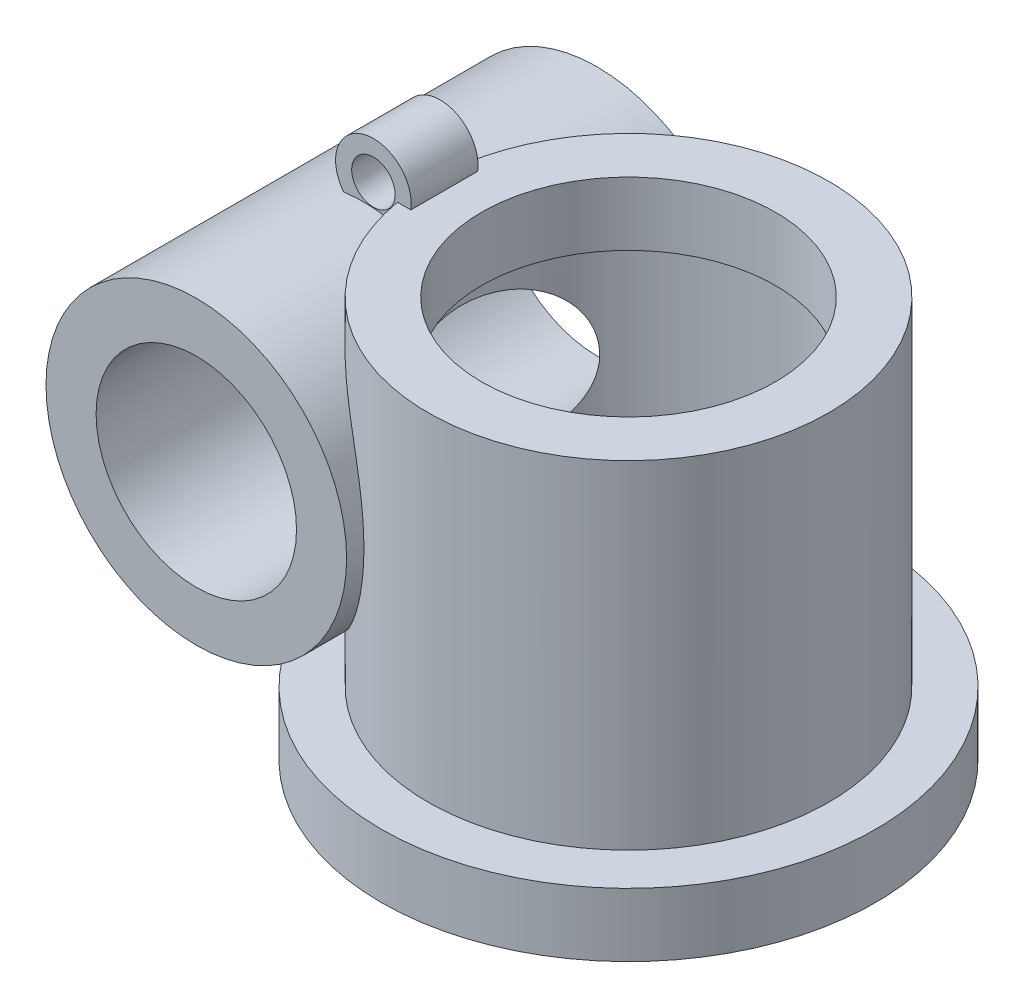
from build123d import *

# Parameters (mm, degrees)
BOSS_EXTRUDE1_DEPTH      = 5
BOSS_EXTRUDE1_DEPTH_BACK = 1
SKETCH1_R                = 3
SKETCH1_R_2              = 2.5
BOSS_EXTRUDE2_DEPTH      = 3
BOSS_EXTRUDE2_DEPTH_BACK = 3
SKETCH2_R                = 2.25
SKETCH2_R_2              = 1.5
SKETCH3_R                = 1.5
CUT_EXTRUDE1_DEPTH       = 10.680826584
SKETCH4_R                = 2.5
CUT_EXTRUDE2_DEPTH       = 9.815804089
BOSS_EXTRUDE3_DEPTH      = 0.5
BOSS_EXTRUDE3_DEPTH_BACK = 0.5
SKETCH5_R                = 0.566074209
SKETCH5_R_2              = 0.324906468
SKETCH6_R                = 3.7
SKETCH6_R_2              = 3
BOSS_EXTRUDE4_DEPTH      = 0.95
BOSS_EXTRUDE5_START      = -0.95
SKETCH7_R                = 2.5
SKETCH7_R_2              = 2.2
BOSS_EXTRUDE5_DEPTH      = 0.95


with BuildPart() as part:
    # Sketch1 → Boss-Extrude1 (new, two sides: drawn at the far end of the back side and taken through both)
    with BuildSketch(Plane(origin=(0, 0, 0), x_dir=(1, 0, 0), z_dir=(0, 1, 0)).offset(-BOSS_EXTRUDE1_DEPTH_BACK)):
        Circle(SKETCH1_R)
        Circle(SKETCH1_R_2, mode=Mode.SUBTRACT)
    extrude(amount=BOSS_EXTRUDE1_DEPTH + BOSS_EXTRUDE1_DEPTH_BACK)

    # Sketch2 → Boss-Extrude2 (add, two sides: drawn at the far end of the back side and taken through both)
    with BuildSketch(Plane.XY.offset(-BOSS_EXTRUDE2_DEPTH_BACK)):
        with Locations((-3.47, 2.5)):
            Circle(SKETCH2_R)
        with Locations((-3.47, 2.5)):
            Circle(SKETCH2_R_2, mode=Mode.SUBTRACT)
    extrude(amount=BOSS_EXTRUDE2_DEPTH + BOSS_EXTRUDE2_DEPTH_BACK)

    # Sketch3 → Cut-Extrude1 (cut, through all)
    with BuildSketch(Plane.XY.offset(3)):
        with Locations((-3.47, 2.5)):
            Circle(SKETCH3_R)
    extrude(amount=-CUT_EXTRUDE1_DEPTH, mode=Mode.SUBTRACT)

    # Sketch4 → Cut-Extrude2 (cut, through all)
    with BuildSketch(Plane(origin=(0, 5, 0), x_dir=(1, 0, 0), z_dir=(0, 1, 0))):
        Circle(SKETCH4_R)
    extrude(amount=-CUT_EXTRUDE2_DEPTH, mode=Mode.SUBTRACT)

    # Sketch5 → Boss-Extrude3 (add, two sides: drawn at the far end of the back side and taken through both)
    with BuildSketch(Plane.XY.offset(-BOSS_EXTRUDE3_DEPTH_BACK)):
        with Locations((-3.318977868, 5.08019985)):
            Circle(SKETCH5_R)
        with Locations((-3.318977868, 5.08019985)):
            Circle(SKETCH5_R_2, mode=Mode.SUBTRACT)
    extrude(amount=BOSS_EXTRUDE3_DEPTH + BOSS_EXTRUDE3_DEPTH_BACK)

    # Sketch6 → Boss-Extrude4 (add)
    with BuildSketch(Plane.XZ.offset(1)):
        Circle(SKETCH6_R)
        Circle(SKETCH6_R_2, mode=Mode.SUBTRACT)
    extrude(amount=-BOSS_EXTRUDE4_DEPTH)

    # Sketch7 → Boss-Extrude5 (add)
    with BuildSketch(Plane(origin=(0, 5, 0), x_dir=(1, 0, 0), z_dir=(0, 1, 0)).offset(BOSS_EXTRUDE5_START)):
        Circle(SKETCH7_R)
        Circle(SKETCH7_R_2, mode=Mode.SUBTRACT)
    extrude(amount=BOSS_EXTRUDE5_DEPTH)


solid = part.part
